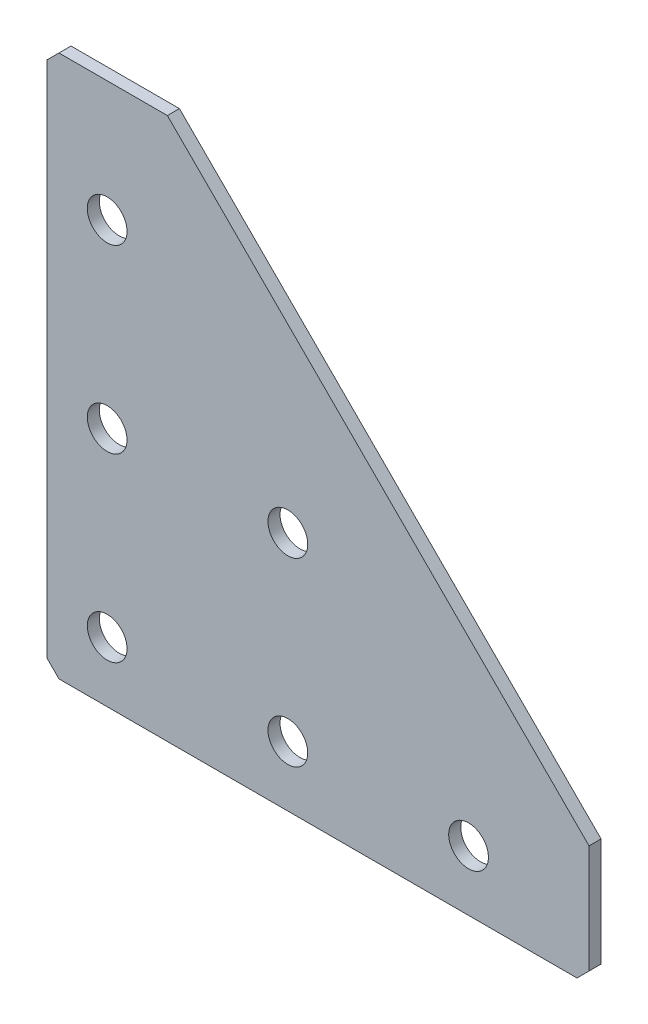
from build123d import *

# Parameters (mm, degrees)
EXTRUDE_1_DEPTH   = 2
HOLE_WIZARD_M61_D = 6.6
CHAMFER_1_SIZE    = 2


with BuildPart() as part:
    # Эскиз1 → Бобышка-Вытянуть1 (new body)
    with BuildSketch(Plane(origin=(0, 0, 0), x_dir=(1, 0, 0), z_dir=(0, 0, -1))):
        Polygon((0, 0), (0, 90), (90, 90), (90, 70), (20, 0), align=None)
    extrude(amount=EXTRUDE_1_DEPTH)

    # Отверстие с зазором M61 (through all)
    with Locations(Plane(origin=(0, 0, -2), x_dir=(1, 0, 0), z_dir=(0, 0, -1))):
        with Locations((40, 80), (10, 80), (10, 50), (10, 20), (70, 80), (40, 50)):
            Hole(HOLE_WIZARD_M61_D / 2)

    # Фаска1
    chamfer_1_edges = [part.edges().sort_by_distance(p)[0] for p in [
        (0, 0, -1),
        (0, -90, -1),
        (90, -90, -1),
    ]]
    chamfer(chamfer_1_edges, length=CHAMFER_1_SIZE)


solid = part.part
